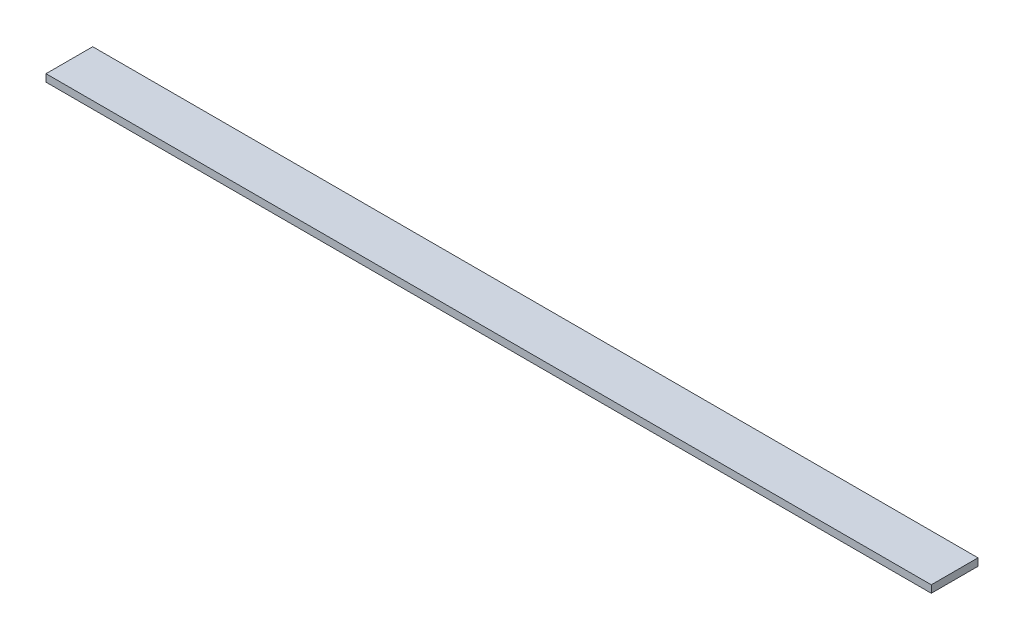
from build123d import *

# Parameters (mm, degrees)
SKETCH1_W           = 1800
SKETCH1_H           = 95
BOSS_EXTRUDE1_DEPTH = 15


with BuildPart() as part:
    # Sketch1 → Boss-Extrude1 (new body)
    with BuildSketch(Plane(origin=(0, 0, 0), x_dir=(1, 0, 0), z_dir=(0, 1, 0))):
        Rectangle(SKETCH1_W, SKETCH1_H)
    extrude(amount=BOSS_EXTRUDE1_DEPTH)


solid = part.part
